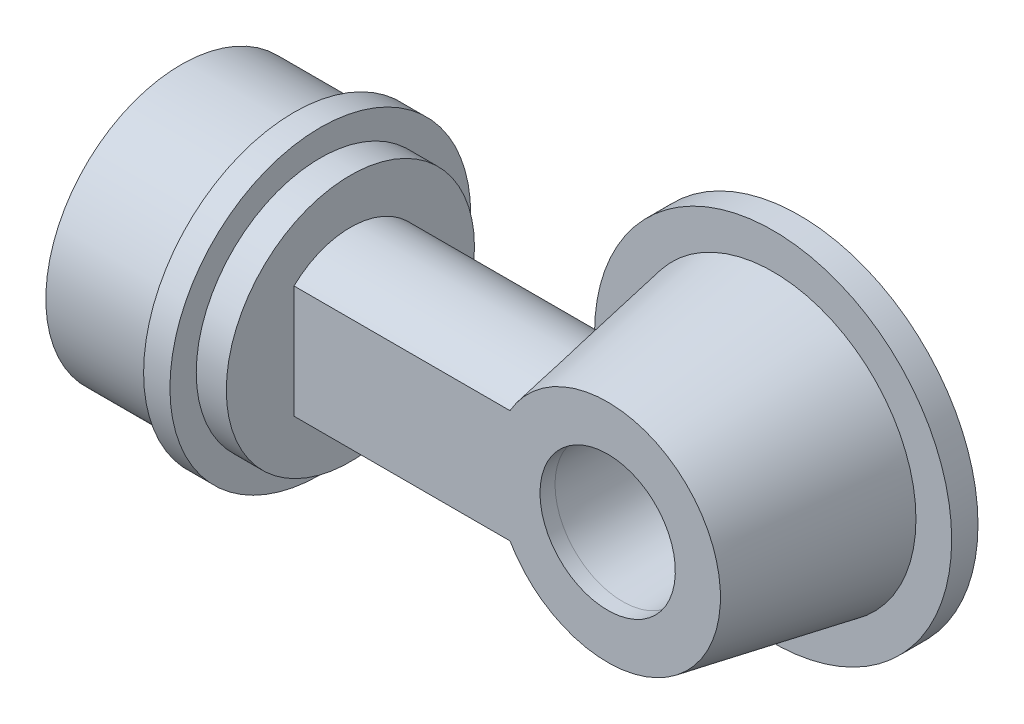
from build123d import *

# Parameters (mm, degrees)
CROQUIS1_R                 = 18
CROQUIS1_R_2               = 15.5
SALIENTE_EXTRUIR1_DEPTH    = 15
CROQUIS2_R                 = 20
CROQUIS2_R_2               = 15.5
SALIENTE_EXTRUIR2_DEPTH    = 3.5
CROQUIS4_R                 = 16.5
CROQUIS4_R_2               = 13.5
SALIENTE_EXTRUIR3_DEPTH    = 4
CROQUIS5_R                 = 16.5
SALIENTE_EXTRUIR4_DEPTH    = 3
SALIENTE_EXTRUIR5_DEPTH    = 31
CROQUIS7_R                 = 15
CROQUIS8_R                 = 19
CROQUIS9_R                 = 13
CROQUIS10_R                = 17
CORTAR_EXTRUIR1_DEPTH      = 41
CORTAR_EXTRUIR1_DEPTH_BACK = 13
CROQUIS12_R                = 15
SALIENTE_EXTRUIR6_DEPTH    = 2
CROQUIS14_R                = 11
SALIENTE_EXTRUIR7_DEPTH    = 22
SALIENTE_EXTRUIR7_TAPER    = 2
CROQUIS17_R                = 9
CROQUIS15_R                = 8.231743071
CROQUIS18_R                = 9
CORTAR_EXTRUIR2_DEPTH      = 57
CROQUIS19_R                = 10.231743071
SALIENTE_EXTRUIR8_DEPTH    = 2
CROQUIS20_R                = 23.75
CROQUIS20_R_2              = 17
SALIENTE_EXTRUIR9_DEPTH    = 3.5


with BuildPart() as part:
    # Croquis1 → Saliente-Extruir1 (new body)
    with BuildSketch(Plane(origin=(0, 0, 0), x_dir=(0, 0, -1), z_dir=(1, 0, 0))):
        Circle(CROQUIS1_R)
        Circle(CROQUIS1_R_2, mode=Mode.SUBTRACT)
    extrude(amount=SALIENTE_EXTRUIR1_DEPTH)

    # Croquis2 → Saliente-Extruir2 (add)
    with BuildSketch(Plane(origin=(15, 0, 0), x_dir=(0, 0, -1), z_dir=(1, 0, 0))):
        Circle(CROQUIS2_R)
        Circle(CROQUIS2_R_2, mode=Mode.SUBTRACT)
    extrude(amount=SALIENTE_EXTRUIR2_DEPTH)

    # Croquis4 → Saliente-Extruir3 (add)
    with BuildSketch(Plane(origin=(18.5, 0, 0), x_dir=(0, 0, -1), z_dir=(1, 0, 0))):
        Circle(CROQUIS4_R)
        Circle(CROQUIS4_R_2, mode=Mode.SUBTRACT)
    extrude(amount=SALIENTE_EXTRUIR3_DEPTH)

    # Croquis5 → Saliente-Extruir4 (add)
    with BuildSketch(Plane(origin=(22.5, 0, 0), x_dir=(0, 0, -1), z_dir=(1, 0, 0))):
        Circle(CROQUIS5_R)
    extrude(amount=-SALIENTE_EXTRUIR4_DEPTH)

    # Croquis6 → Saliente-Extruir5 (add)
    with BuildSketch(Plane(origin=(22.5, 0, 0), x_dir=(0, 0, -1), z_dir=(1, 0, 0))):
        with BuildLine():
            Line((-7.5, 7.5), (-7.5, -7.5))
            ThreePointArc((-7.5, -7.5), (0, -10.5), (7.5, -7.5))
            Line((7.5, -7.5), (7.5, 7.5))
            ThreePointArc((7.5, 7.5), (0, 10.5), (-7.5, 7.5))
        make_face()
        with BuildLine():
            Line((-5.5, 6.590315858), (-5.5, -6.590315858))
            ThreePointArc((-5.5, -6.590315858), (0, -8.5), (5.5, -6.590315858))
            Line((5.5, -6.590315858), (5.5, 6.590315858))
            ThreePointArc((5.5, 6.590315858), (0, 8.5), (-5.5, 6.590315858))
        make_face(mode=Mode.SUBTRACT)
    extrude(amount=SALIENTE_EXTRUIR5_DEPTH)

    # Croquis7 → Recubrir1 section 0
    with BuildSketch(Plane.XY.offset(7.5)):
        with Locations((64.212142643, 0)):
            Circle(CROQUIS7_R)
    # Croquis8 → Recubrir1 section 1
    with BuildSketch(Plane.XY.offset(-14.5)):
        with Locations((64.212142643, 0)):
            Circle(CROQUIS8_R)
    loft()

    # Croquis9 → Cortar-Recubrir1 section 0
    with BuildSketch(Plane.XY.offset(7.5)):
        with Locations((64.212142643, 0)):
            Circle(CROQUIS9_R)
    # Croquis10 → Cortar-Recubrir1 section 1
    with BuildSketch(Plane(origin=(0, 0, -14.5), x_dir=(-1, 0, 0), z_dir=(0, 0, -1))):
        with Locations((-64.212142643, 0)):
            Circle(CROQUIS10_R)
    loft(mode=Mode.SUBTRACT)

    # Croquis11 → Cortar-Extruir1 (cut, two sides)
    with BuildSketch(Plane(origin=(22.5, 0, 0), x_dir=(0, 0, -1), z_dir=(1, 0, 0))) as cortar_extruir1_sk:
        with BuildLine():
            Line((-5.5, 6.590315858), (-5.5, -6.590315858))
            ThreePointArc((-5.5, -6.590315858), (0, -8.5), (5.5, -6.590315858))
            Line((5.5, -6.590315858), (5.5, 6.590315858))
            ThreePointArc((5.5, 6.590315858), (0, 8.5), (-5.5, 6.590315858))
        make_face()
    extrude(amount=CORTAR_EXTRUIR1_DEPTH, mode=Mode.SUBTRACT)
    extrude(cortar_extruir1_sk.sketch, amount=-CORTAR_EXTRUIR1_DEPTH_BACK, mode=Mode.SUBTRACT)

    # Croquis12 → Saliente-Extruir6 (add)
    with BuildSketch(Plane.XY.offset(7.5)):
        with Locations((64.212142643, 0)):
            Circle(CROQUIS12_R)
    extrude(amount=-SALIENTE_EXTRUIR6_DEPTH)

    # Croquis14 → Saliente-Extruir7 (add)
    with BuildSketch(Plane(origin=(0, 0, 5.5), x_dir=(-1, 0, 0), z_dir=(0, 0, -1))):
        with Locations((-64.212142643, 0)):
            Circle(CROQUIS14_R)
    extrude(amount=SALIENTE_EXTRUIR7_DEPTH, taper=SALIENTE_EXTRUIR7_TAPER)

    # Croquis17 → Cortar-Recubrir2 section 0
    with BuildSketch(Plane(origin=(0, 0, 5.5), x_dir=(-1, 0, 0), z_dir=(0, 0, -1))):
        with Locations((-64.212142643, 0)):
            Circle(CROQUIS17_R)
    # Croquis15 → Cortar-Recubrir2 section 1
    with BuildSketch(Plane(origin=(0, 0, -16.5), x_dir=(-1, 0, 0), z_dir=(0, 0, -1))):
        with Locations((-64.212142643, 0)):
            Circle(CROQUIS15_R)
    loft(mode=Mode.SUBTRACT)

    # Croquis18 → Cortar-Extruir2 (cut)
    with BuildSketch(Plane(origin=(0, 0, 5.5), x_dir=(-1, 0, 0), z_dir=(0, 0, -1))):
        with Locations((-64.212142643, 0)):
            Circle(CROQUIS18_R)
    extrude(amount=-CORTAR_EXTRUIR2_DEPTH, mode=Mode.SUBTRACT)

    # Croquis19 → Saliente-Extruir8 (add)
    with BuildSketch(Plane(origin=(0, 0, -16.5), x_dir=(-1, 0, 0), z_dir=(0, 0, -1))):
        with Locations((-64.212142643, 0)):
            Circle(CROQUIS19_R)
    extrude(amount=-SALIENTE_EXTRUIR8_DEPTH)

    # Croquis20 → Saliente-Extruir9 (add)
    with BuildSketch(Plane(origin=(0, 0, -14.5), x_dir=(-1, 0, 0), z_dir=(0, 0, -1))):
        with Locations((-64.212142643, 0)):
            Circle(CROQUIS20_R)
        with Locations((-64.212142643, 0)):
            Circle(CROQUIS20_R_2, mode=Mode.SUBTRACT)
    extrude(amount=SALIENTE_EXTRUIR9_DEPTH)


solid = part.part
